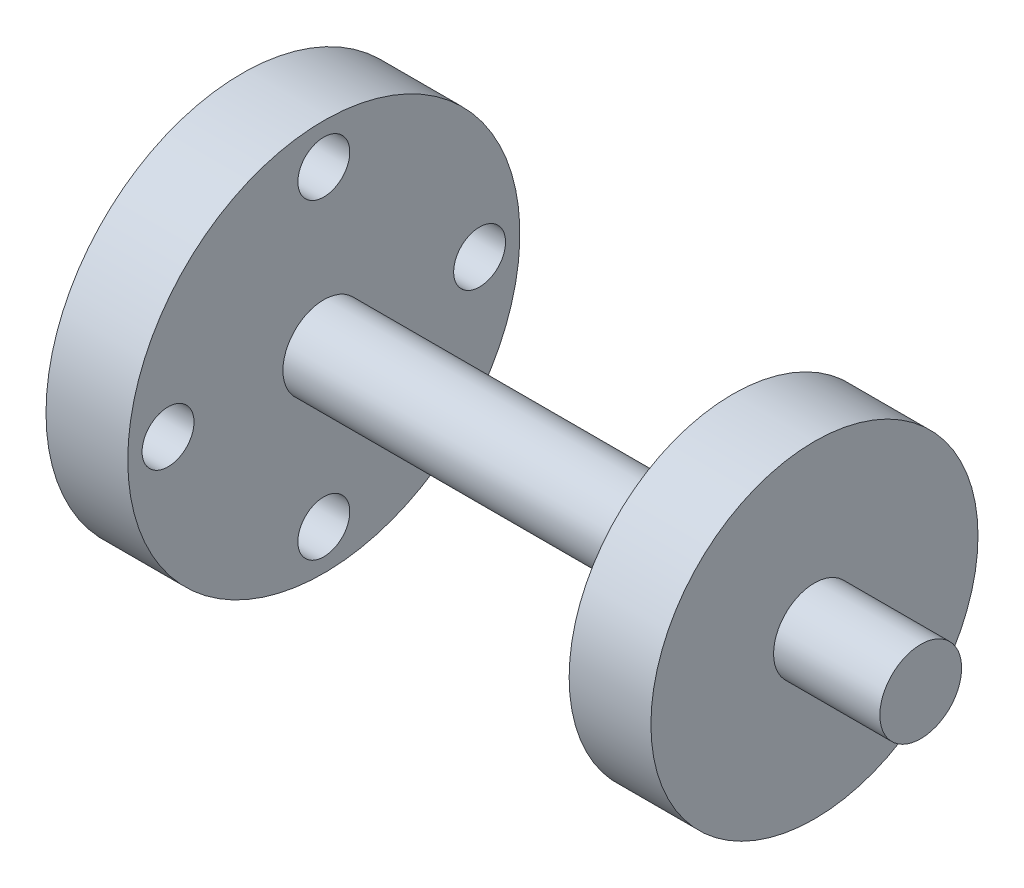
from build123d import *

# Parameters (mm, degrees)
SKETCH3_R          = 3.175
CUT_EXTRUDE1_DEPTH = 10


with BuildPart() as part:
    # Sketch1 → Revolve1 (revolve)
    with BuildSketch(Plane.XY):
        Polygon((83, 5), (70, 5), (70, 20), (60, 20), (60, 5), (10, 5), (10, 23.975), (0, 23.975), (0, 0), (83, 0), align=None)
    revolve(axis=Axis((0, 0, 0), (1, 0, 0)))

    # Sketch3 → Cut-Extrude1 (cut)
    with BuildSketch(Plane.ZY):
        with Locations((0, 19.05)):
            Circle(SKETCH3_R)
        with Locations((19.05, 0)):
            Circle(SKETCH3_R)
        with Locations((0, -19.05)):
            Circle(SKETCH3_R)
        with Locations((-19.05, 0)):
            Circle(SKETCH3_R)
    extrude(amount=-CUT_EXTRUDE1_DEPTH, mode=Mode.SUBTRACT)


solid = part.part
